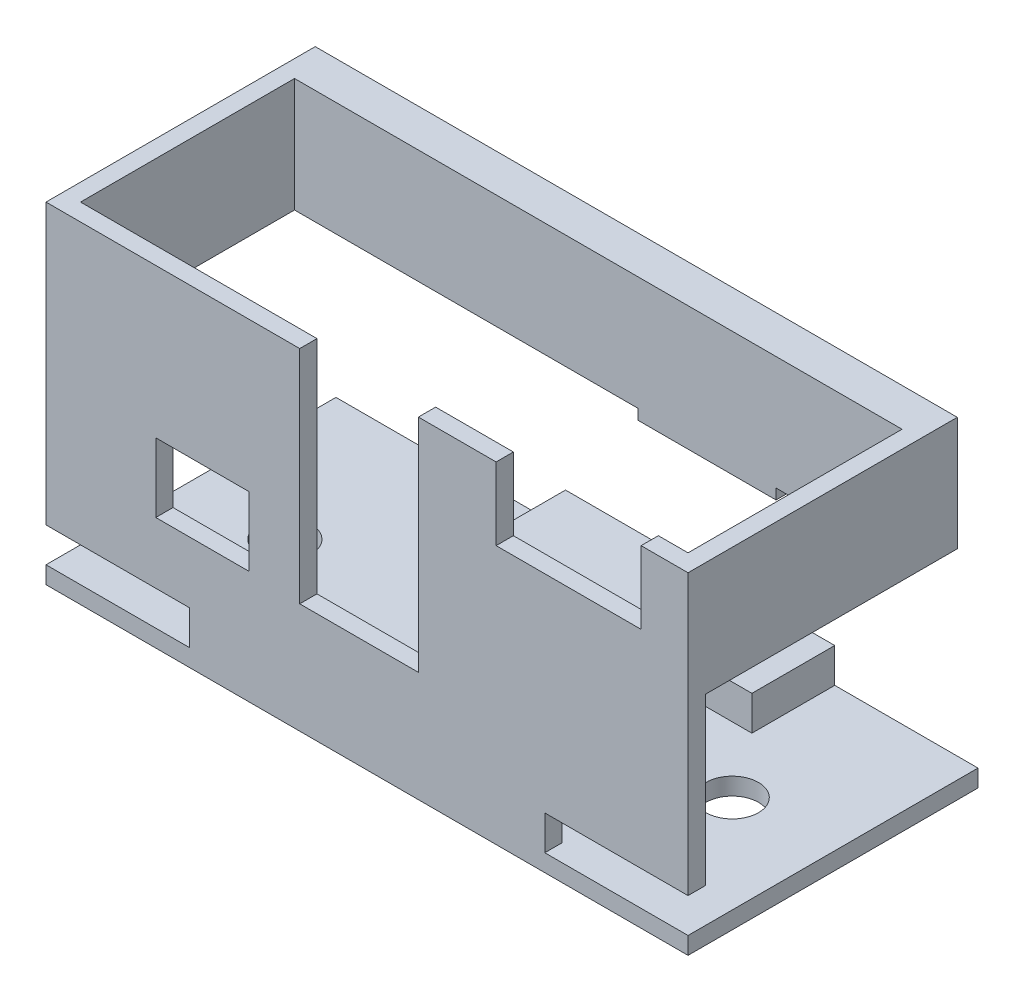
from build123d import *

# Parameters (mm, degrees)
SKETCH1_W               = 46.5
SKETCH1_H               = 24
BOSS_EXTRUDE1_DEPTH     = 21
SHELL1_T                = -1.25
SKETCH2_W               = 19.75
SKETCH2_H               = 14.5
CUT_EXTRUDE1_DEPTH      = 47.5
SKETCH7_W               = 10.375
SKETCH7_H               = 2.5
CUT_EXTRUDE5_DEPTH      = 1.25
SKETCH9_W               = 19.5
SKETCH9_H               = 6
BOSS_EXTRUDE3_DEPTH     = 2.5
CUT_EXTRUDE7_START      = -45.25
SKETCH12_W              = 1.5
SKETCH12_H              = 8.25
CUT_EXTRUDE7_DEPTH      = 46.25
CUT_EXTRUDE7_DEPTH_BACK = 47.5
SKETCH13_W              = 2.75
SKETCH13_H              = 8.25
BOSS_EXTRUDE4_DEPTH     = 44
SKETCH15_W              = 10
SKETCH15_H              = 2.75
BOSS_EXTRUDE5_DEPTH     = 0.75
CUT_EXTRUDE8_REACH      = 23
SKETCH18_W              = 6.76
SKETCH18_H              = 5
CUT_EXTRUDE9_REACH      = 23
SKETCH22_W              = 8.593751287
SKETCH22_H              = 16.011767213
CUT_EXTRUDE15_REACH     = 23
SKETCH25_W              = 10
SKETCH25_H              = 4.5
CUT_EXTRUDE16_REACH     = 26
SKETCH6_R               = 1.9


with BuildPart() as part:
    # Sketch1 → Boss-Extrude1 (new body)
    with BuildSketch(Plane.XY):
        with Locations((22, 12)):
            Rectangle(SKETCH1_W, SKETCH1_H)
    extrude(amount=-BOSS_EXTRUDE1_DEPTH)

    # Shell1
    shell1_openings = [part.faces().sort_by_distance(p)[0] for p in [
        (22, 12, -21),
        (22, 24, -10.5),
    ]]
    offset(amount=SHELL1_T, openings=shell1_openings, kind=Kind.INTERSECTION)

    # Sketch2 → Cut-Extrude1 (cut, through all)
    with BuildSketch(Plane.ZY.offset(1.25)):
        with Locations((-11.125, 8.5)):
            Rectangle(SKETCH2_W, SKETCH2_H)
    extrude(amount=-CUT_EXTRUDE1_DEPTH, mode=Mode.SUBTRACT)

    # Sketch7 → Cut-Extrude5 (cut)
    with BuildSketch(Plane.XY):
        with Locations((40.0625, 2.5)):
            Rectangle(SKETCH7_W, SKETCH7_H)
        with Locations((3.9375, 2.5)):
            Rectangle(SKETCH7_W, SKETCH7_H)
    extrude(amount=-CUT_EXTRUDE5_DEPTH, mode=Mode.SUBTRACT)

    # Sketch9 → Boss-Extrude3 (add)
    with BuildSketch(Plane(origin=(0, 1.25, 0), x_dir=(1, 0, 0), z_dir=(0, 1, 0))):
        with Locations((25.125, 18)):
            Rectangle(SKETCH9_W, SKETCH9_H)
    extrude(amount=BOSS_EXTRUDE3_DEPTH)

    # Sketch12 → Cut-Extrude7 (cut, two sides)
    with BuildSketch(Plane(origin=(45.25, 0, 0), x_dir=(0, 0, -1), z_dir=(1, 0, 0)).offset(CUT_EXTRUDE7_START)) as cut_extrude7_sk:
        with Locations((20.25, 19.875)):
            Rectangle(SKETCH12_W, SKETCH12_H)
    extrude(amount=CUT_EXTRUDE7_DEPTH, mode=Mode.SUBTRACT)
    extrude(cut_extrude7_sk.sketch, amount=-CUT_EXTRUDE7_DEPTH_BACK, mode=Mode.SUBTRACT)

    # Sketch13 → Boss-Extrude4 (add)
    with BuildSketch(Plane(origin=(0, 0, 0), x_dir=(0, 0, -1), z_dir=(1, 0, 0))):
        with Locations((18.125, 19.875)):
            Rectangle(SKETCH13_W, SKETCH13_H)
    extrude(amount=BOSS_EXTRUDE4_DEPTH)

    # Sketch15 → Boss-Extrude5 (add)
    with BuildSketch(Plane.XZ.offset(-15.75)):
        with Locations((29.875, -18.125)):
            Rectangle(SKETCH15_W, SKETCH15_H)
    extrude(amount=BOSS_EXTRUDE5_DEPTH)

    # Sketch18 → Cut-Extrude8 (cut, up to next)
    with BuildSketch(Plane.XY, mode=Mode.PRIVATE) as cut_extrude8_sk1:
        with Locations((10.08, 10.69)):
            Rectangle(SKETCH18_W, SKETCH18_H)
    cut_extrude8_tool1 = extrude(cut_extrude8_sk1.sketch, amount=-CUT_EXTRUDE8_REACH, mode=Mode.PRIVATE) & part.part
    add(cut_extrude8_tool1.solids().sort_by_distance((10.08, 10.69, 0))[0], mode=Mode.SUBTRACT)

    # Sketch22 → Cut-Extrude9 (cut, up to next)
    with BuildSketch(Plane.XY, mode=Mode.PRIVATE) as cut_extrude9_sk1:
        with Locations((21.422492142, 15.994116394)):
            Rectangle(SKETCH22_W, SKETCH22_H)
    cut_extrude9_tool1 = extrude(cut_extrude9_sk1.sketch, amount=-CUT_EXTRUDE9_REACH, mode=Mode.PRIVATE) & part.part
    add(cut_extrude9_tool1.solids().sort_by_distance((21.422492, 15.994116, 0))[0], mode=Mode.SUBTRACT)

    # Sketch25 → Cut-Extrude15 (cut, up to next)
    with BuildSketch(Plane.XY, mode=Mode.PRIVATE) as cut_extrude15_sk1:
        Polygon((31.35, 18.75), (41.85, 18.75), (41.85, 24), (41.6, 24), (41.6, 19.5), (31.6, 19.5), (31.6, 24), (31.35, 24), align=None)
    cut_extrude15_tool1 = extrude(cut_extrude15_sk1.sketch, amount=-CUT_EXTRUDE15_REACH, mode=Mode.PRIVATE) & part.part
    add(cut_extrude15_tool1.solids().sort_by_distance((31.475, 23.882606, 0))[0], mode=Mode.SUBTRACT)
    # Sketch25 → Cut-Extrude15 (cut, up to next)
    with BuildSketch(Plane.XY, mode=Mode.PRIVATE) as cut_extrude15_sk2:
        with Locations((36.6, 21.75)):
            Rectangle(SKETCH25_W, SKETCH25_H)
    cut_extrude15_tool2 = extrude(cut_extrude15_sk2.sketch, amount=-CUT_EXTRUDE15_REACH, mode=Mode.PRIVATE) & part.part
    add(cut_extrude15_tool2.solids().sort_by_distance((36.6, 21.75, 0))[0], mode=Mode.SUBTRACT)

    # Sketch6 → Cut-Extrude16 (cut, up to next)
    with BuildSketch(Plane(origin=(0, 0, 0), x_dir=(-1, 0, 0), z_dir=(0, -1, 0)), mode=Mode.PRIVATE) as cut_extrude16_sk1:
        with Locations((-5.8, 10.25)):
            Circle(SKETCH6_R)
    cut_extrude16_tool1 = extrude(cut_extrude16_sk1.sketch, amount=-CUT_EXTRUDE16_REACH, mode=Mode.PRIVATE) & part.part
    add(cut_extrude16_tool1.solids().sort_by_distance((5.8, 0, -10.25))[0], mode=Mode.SUBTRACT)
    # Sketch6 → Cut-Extrude16 (cut, up to next)
    with BuildSketch(Plane(origin=(0, 0, 0), x_dir=(-1, 0, 0), z_dir=(0, -1, 0)), mode=Mode.PRIVATE) as cut_extrude16_sk2:
        with Locations((-38.2, 10.25)):
            Circle(SKETCH6_R)
    cut_extrude16_tool2 = extrude(cut_extrude16_sk2.sketch, amount=-CUT_EXTRUDE16_REACH, mode=Mode.PRIVATE) & part.part
    add(cut_extrude16_tool2.solids().sort_by_distance((38.2, 0, -10.25))[0], mode=Mode.SUBTRACT)


solid = part.part
